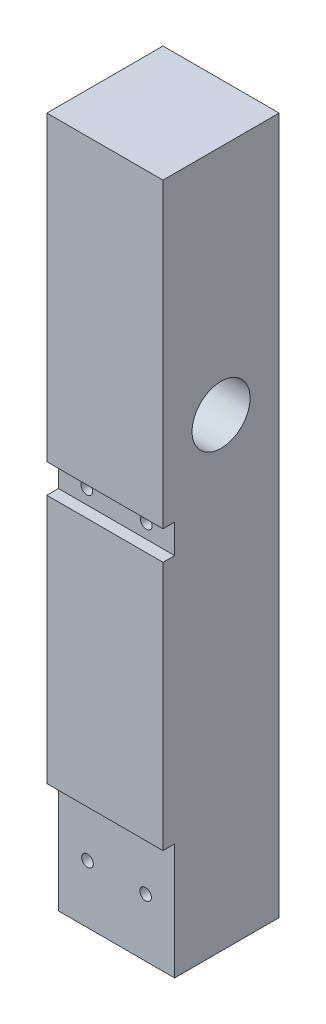
from build123d import *

# Parameters (mm, degrees)
SKETCH1_W           = 20
SKETCH1_H           = 120
SKETCH1_R           = 2.5
BOSS_EXTRUDE2_DEPTH = 20
SKETCH10_R          = 5
CUT_EXTRUDE1_DEPTH  = 10
SKETCH11_R          = 1
CUT_EXTRUDE2_DEPTH  = 21
SKETCH12_R          = 2
CUT_EXTRUDE3_DEPTH  = 5
SKETCH13_R          = 1
CUT_EXTRUDE4_DEPTH  = 21
SKETCH14_R          = 2
CUT_EXTRUDE5_DEPTH  = 5
SKETCH16_W          = 20
SKETCH16_H          = 5
SKETCH16_H_2        = 20
CUT_EXTRUDE6_DEPTH  = 2


with BuildPart() as part:
    # Sketch1 → Boss-Extrude2 (new body)
    with BuildSketch(Plane(origin=(0, 0, 0), x_dir=(0, 0, -1), z_dir=(1, 0, 0))):
        with Locations((10, 60)):
            Rectangle(SKETCH1_W, SKETCH1_H)
        with Locations((10, 80)):
            Circle(SKETCH1_R, mode=Mode.SUBTRACT)
    extrude(amount=-BOSS_EXTRUDE2_DEPTH)

    # Sketch10 → Cut-Extrude1 (cut)
    with BuildSketch(Plane(origin=(0, 0, 0), x_dir=(0, 0, -1), z_dir=(1, 0, 0))):
        with Locations((10, 80)):
            Circle(SKETCH10_R)
    extrude(amount=-CUT_EXTRUDE1_DEPTH, mode=Mode.SUBTRACT)

    # Sketch11 → Cut-Extrude2 (cut, through all)
    with BuildSketch(Plane.XY):
        with Locations((-15, 10)):
            Circle(SKETCH11_R)
        with Locations((-5, 10)):
            Circle(SKETCH11_R)
    extrude(amount=-CUT_EXTRUDE2_DEPTH, mode=Mode.SUBTRACT)

    # Sketch12 → Cut-Extrude3 (cut)
    with BuildSketch(Plane(origin=(0, 0, -20), x_dir=(-1, 0, 0), z_dir=(0, 0, -1))):
        with Locations((5, 10)):
            Circle(SKETCH12_R)
        with Locations((15, 10)):
            Circle(SKETCH12_R)
    extrude(amount=-CUT_EXTRUDE3_DEPTH, mode=Mode.SUBTRACT)

    # Sketch13 → Cut-Extrude4 (cut, through all)
    with BuildSketch(Plane(origin=(0, 0, -20), x_dir=(-1, 0, 0), z_dir=(0, 0, -1))):
        with Locations((4.880538742, 65.5)):
            Circle(SKETCH13_R)
        with Locations((15.119461258, 65.5)):
            Circle(SKETCH13_R)
    extrude(amount=-CUT_EXTRUDE4_DEPTH, mode=Mode.SUBTRACT)

    # Sketch14 → Cut-Extrude5 (cut)
    with BuildSketch(Plane(origin=(0, 0, -20), x_dir=(-1, 0, 0), z_dir=(0, 0, -1))):
        with Locations((4.880538742, 65.5)):
            Circle(SKETCH14_R)
        with Locations((15.119461258, 65.5)):
            Circle(SKETCH14_R)
    extrude(amount=-CUT_EXTRUDE5_DEPTH, mode=Mode.SUBTRACT)

    # Sketch16 → Cut-Extrude6 (cut)
    with BuildSketch(Plane.XY):
        with Locations((-10, 65.5)):
            Rectangle(SKETCH16_W, SKETCH16_H)
        with Locations((-10, 10)):
            Rectangle(SKETCH16_W, SKETCH16_H_2)
    extrude(amount=-CUT_EXTRUDE6_DEPTH, mode=Mode.SUBTRACT)


solid = part.part
